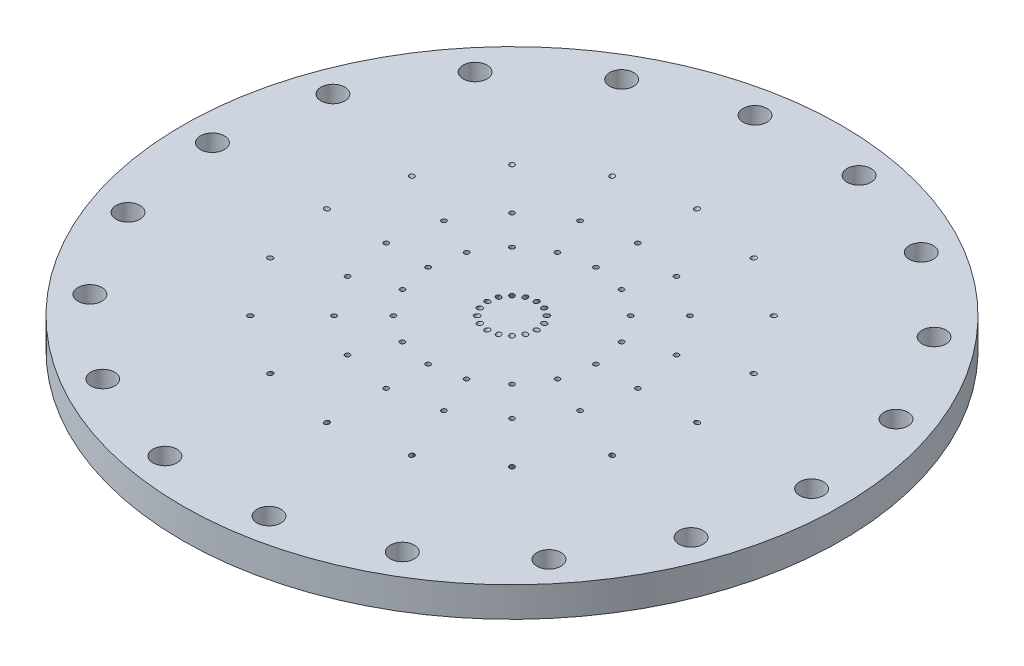
from build123d import *

# Parameters (mm, degrees)
SKETCH1_R           = 69.85
BOSS_EXTRUDE1_DEPTH = 6.35
SKETCH2_R           = 69.85
BOSS_EXTRUDE2_DEPTH = 6.35
SKETCH4_R           = 6.35
CUT_EXTRUDE1_DEPTH  = 6.35
SKETCH5_R           = 26.19375
SKETCH5_R_2         = 12.7
CUT_EXTRUDE2_DEPTH  = 6.35
SKETCH6_R           = 36.83
SKETCH6_R_2         = 31.75
CUT_EXTRUDE3_DEPTH  = 6.35
CUT_EXTRUDE4_START  = 8.505524
SKETCH8_R           = 0.508
CUT_EXTRUDE4_DEPTH  = 15.251285
SKETCH9_R           = 0.508
CUT_EXTRUDE5_DEPTH  = 12.7
CUT_EXTRUDE6_START  = 11.006381
SKETCH11_R          = 0.508
CUT_EXTRUDE6_DEPTH  = 7.918937
CIRPATTERN1_COUNT   = 16
SKETCH12_R          = 2.54
CUT_EXTRUDE7_DEPTH  = 13.7
CIRPATTERN2_COUNT   = 18
SKETCH13_R          = 10.3632
SKETCH13_R_2        = 7.7216
CUT_EXTRUDE8_DEPTH  = 1.3208
SKETCH14_R          = 30.2133
SKETCH14_R_2        = 27.5717
CUT_EXTRUDE9_DEPTH  = 1.3208
SKETCH16_R          = 46.0883
SKETCH16_R_2        = 43.4467
CUT_EXTRUDE10_DEPTH = 1.3208
SKETCH20_R          = 69.85
CUT_EXTRUDE11_DEPTH = 6.35


with BuildPart() as part:
    # Sketch1 → Boss-Extrude1 (new body)
    with BuildSketch(Plane(origin=(0, 0, 0), x_dir=(1, 0, 0), z_dir=(0, 1, 0))):
        Circle(SKETCH1_R)
    extrude(amount=BOSS_EXTRUDE1_DEPTH)

    # Sketch2 → Boss-Extrude2 (add)
    with BuildSketch(Plane.XZ):
        Circle(SKETCH2_R)
    extrude(amount=BOSS_EXTRUDE2_DEPTH)

    # Sketch4 → Cut-Extrude1 (cut)
    with BuildSketch(Plane(origin=(0, 6.35, 0), x_dir=(1, 0, 0), z_dir=(0, 1, 0))):
        Circle(SKETCH4_R)
    extrude(amount=-CUT_EXTRUDE1_DEPTH, mode=Mode.SUBTRACT)

    # Sketch5 → Cut-Extrude2 (cut)
    with BuildSketch(Plane(origin=(0, 6.35, 0), x_dir=(1, 0, 0), z_dir=(0, 1, 0))):
        Circle(SKETCH5_R)
        Circle(SKETCH5_R_2, mode=Mode.SUBTRACT)
    extrude(amount=-CUT_EXTRUDE2_DEPTH, mode=Mode.SUBTRACT)

    # Sketch6 → Cut-Extrude3 (cut)
    with BuildSketch(Plane(origin=(0, 6.35, 0), x_dir=(1, 0, 0), z_dir=(0, 1, 0))):
        Circle(SKETCH6_R)
        Circle(SKETCH6_R_2, mode=Mode.SUBTRACT)
    extrude(amount=-CUT_EXTRUDE3_DEPTH, mode=Mode.SUBTRACT)

    # Sketch8 → Cut-Extrude4 (cut)
    with BuildSketch(Plane(origin=(-1.740960292, 3.015431679, 0), x_dir=(-0.866025404, -0.5, 0), z_dir=(-0.5, 0.866025404, 0)).offset(CUT_EXTRUDE4_START)):
        with Locations((33.970863359, 0)):
            Circle(SKETCH8_R)
    cut_extrude4 = extrude(amount=CUT_EXTRUDE4_DEPTH, mode=Mode.SUBTRACT)

    # Sketch9 → Cut-Extrude5 (cut)
    with BuildSketch(Plane.XZ.offset(6.35)):
        with Locations((-26.67, 0)):
            Circle(SKETCH9_R)
        with Locations((-17.78, 0)):
            Circle(SKETCH9_R)
    cut_extrude5 = extrude(amount=-CUT_EXTRUDE5_DEPTH, mode=Mode.SUBTRACT)

    # Sketch11 → Cut-Extrude6 (cut)
    with BuildSketch(Plane(origin=(-10.621968306, -18.397788783, 0), x_dir=(0.866025404, -0.5, 0), z_dir=(0.5, 0.866025404, 0)).offset(CUT_EXTRUDE6_START)):
        with Locations((-4.52396584, 0)):
            Circle(SKETCH11_R)
    cut_extrude6 = extrude(amount=CUT_EXTRUDE6_DEPTH, mode=Mode.SUBTRACT)

    # CirPattern1: Cut-Extrude4, Cut-Extrude5, Cut-Extrude6 ×16 about axis
    cirpattern1_axis = Axis((0, 0, 0), (0, 1, 0))
    for i in range(1, CIRPATTERN1_COUNT):
        add(cut_extrude4.rotate(cirpattern1_axis, i * 360 / CIRPATTERN1_COUNT), mode=Mode.SUBTRACT)
        add(cut_extrude5.rotate(cirpattern1_axis, i * 360 / CIRPATTERN1_COUNT), mode=Mode.SUBTRACT)
        add(cut_extrude6.rotate(cirpattern1_axis, i * 360 / CIRPATTERN1_COUNT), mode=Mode.SUBTRACT)

    # Sketch12 → Cut-Extrude7 (cut, through all)
    with BuildSketch(Plane(origin=(0, 6.35, 0), x_dir=(1, 0, 0), z_dir=(0, 1, 0))):
        with Locations((63.5, 0)):
            Circle(SKETCH12_R)
    cut_extrude7 = extrude(amount=-CUT_EXTRUDE7_DEPTH, mode=Mode.SUBTRACT)

    # CirPattern2: Cut-Extrude7 ×18 about axis
    cirpattern2_axis = Axis((0, 0, 0), (0, 1, 0))
    for i in range(1, CIRPATTERN2_COUNT):
        add(cut_extrude7.rotate(cirpattern2_axis, i * 360 / CIRPATTERN2_COUNT), mode=Mode.SUBTRACT)

    # Sketch13 → Cut-Extrude8 (cut)
    with BuildSketch(Plane(origin=(0, 6.35, 0), x_dir=(1, 0, 0), z_dir=(0, 1, 0))):
        Circle(SKETCH13_R)
        Circle(SKETCH13_R_2, mode=Mode.SUBTRACT)
    extrude(amount=-CUT_EXTRUDE8_DEPTH, mode=Mode.SUBTRACT)

    # Sketch14 → Cut-Extrude9 (cut)
    with BuildSketch(Plane(origin=(0, 6.35, 0), x_dir=(1, 0, 0), z_dir=(0, 1, 0))):
        Circle(SKETCH14_R)
        Circle(SKETCH14_R_2, mode=Mode.SUBTRACT)
    extrude(amount=-CUT_EXTRUDE9_DEPTH, mode=Mode.SUBTRACT)

    # Sketch16 → Cut-Extrude10 (cut)
    with BuildSketch(Plane(origin=(0, 6.35, 0), x_dir=(1, 0, 0), z_dir=(0, 1, 0))):
        Circle(SKETCH16_R)
        Circle(SKETCH16_R_2, mode=Mode.SUBTRACT)
    extrude(amount=-CUT_EXTRUDE10_DEPTH, mode=Mode.SUBTRACT)

    # Sketch20 → Cut-Extrude11 (cut)
    with BuildSketch(Plane(origin=(0, 6.35, 0), x_dir=(1, 0, 0), z_dir=(0, 1, 0))):
        Circle(SKETCH20_R)
    extrude(amount=-CUT_EXTRUDE11_DEPTH, mode=Mode.SUBTRACT)


solid = part.part
